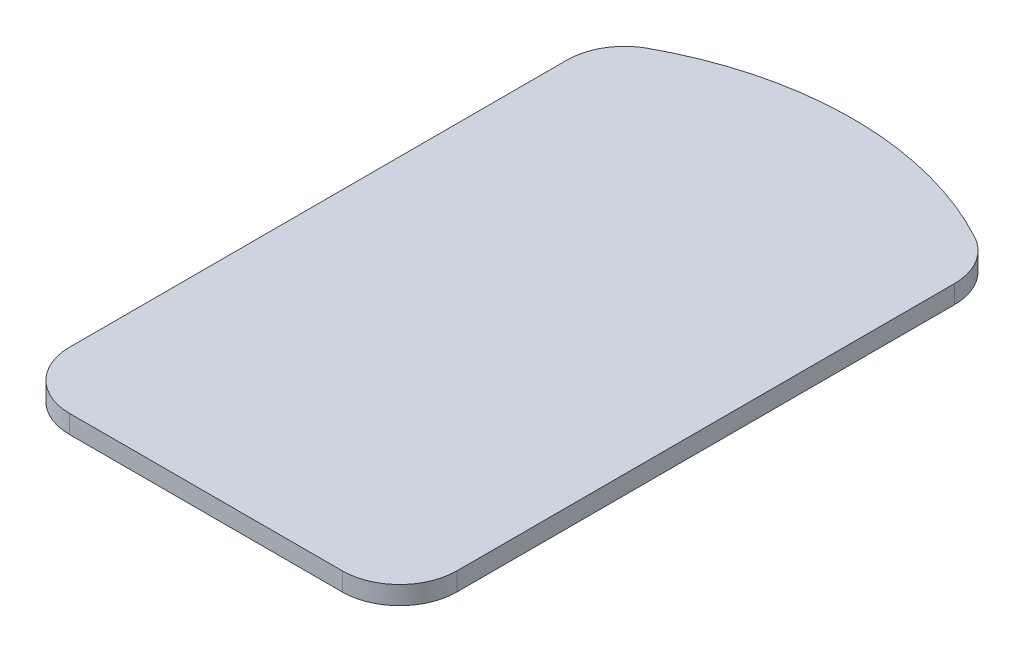
from build123d import *

# Parameters (mm, degrees)
BOSS_EXTRUDE1_DEPTH = 1.6
FILLET1_R           = 5


with BuildPart() as part:
    # Sketch2 → Boss-Extrude1 (new body)
    with BuildSketch(Plane(origin=(0, 0, 0), x_dir=(1, 0, 0), z_dir=(0, 1, 0))):
        with BuildLine():
            Line((-83.305877437, -49.06713814), (-83.305877437, 2.106985575))
            ThreePointArc((-83.305877437, 2.106985575), (-100.196877437, 7.345674781), (-117.087877437, 2.106985575))
            Line((-117.087877437, 2.106985575), (-117.087877437, -49.06713814))
            Line((-117.087877437, -49.06713814), (-83.305877437, -49.06713814))
        make_face()
    extrude(amount=BOSS_EXTRUDE1_DEPTH)

    # Fillet1
    fillet1_edges = [part.edges().sort_by_distance(p)[0] for p in [
        (-83.305877437, 0.8, -2.106985575),
        (-83.305877437, 0.8, 49.06713814),
        (-117.087877437, 0.8, 49.06713814),
        (-117.087877437, 0.8, -2.106985575),
    ]]
    fillet(fillet1_edges, radius=FILLET1_R)


solid = part.part
